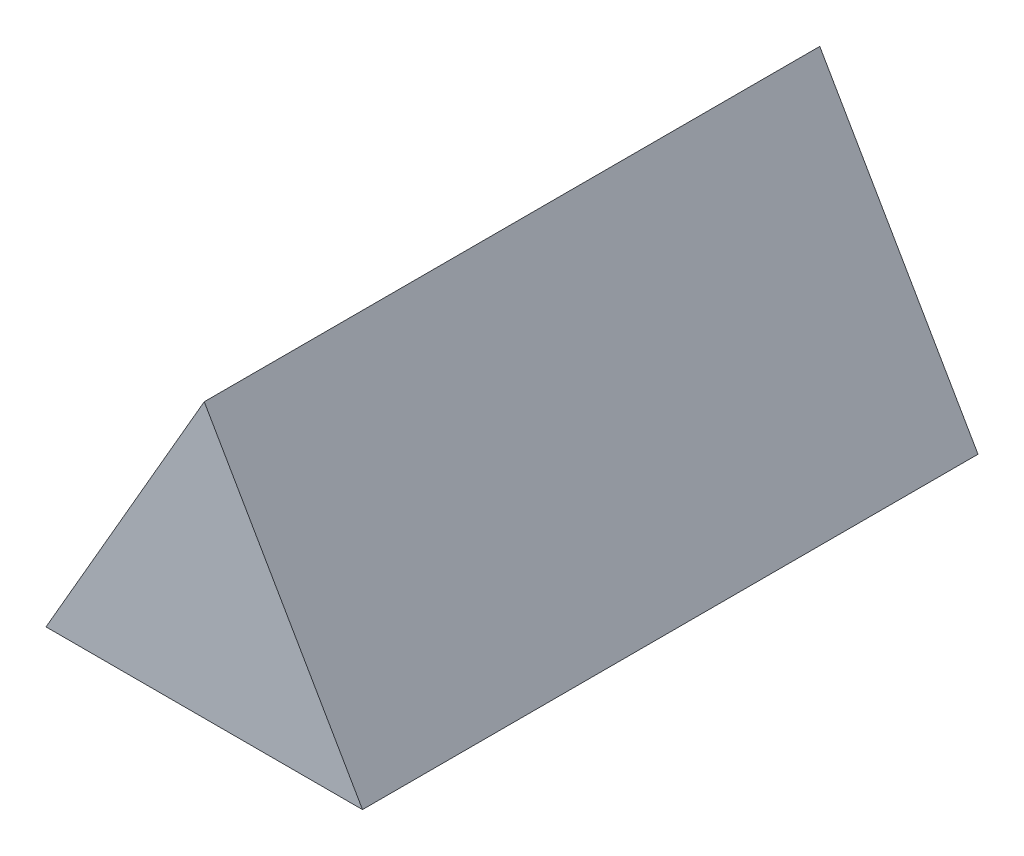
from build123d import *

# Parameters (mm, degrees)
ESTRUSIONE_ESTRUSIONE1_DEPTH = 160


with BuildPart() as part:
    # Schizzo1 → Estrusione-Estrusione1 (new body)
    with BuildSketch(Plane.XY):
        Polygon((0, 47.5), (-41.13620668, -23.75), (41.13620668, -23.75), align=None)
    extrude(amount=ESTRUSIONE_ESTRUSIONE1_DEPTH)


solid = part.part
